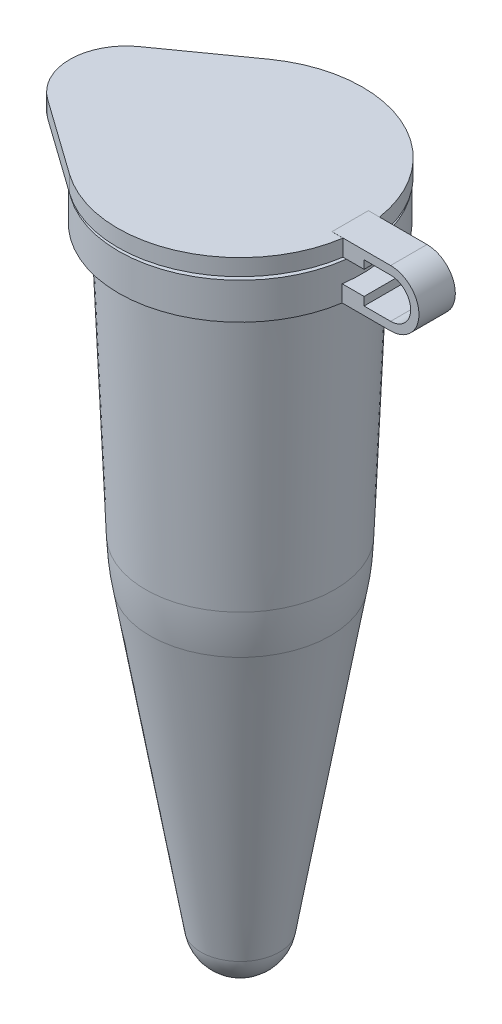
from build123d import *

# Parameters (mm, degrees)
SKETCH1_R           = 3.7338
SKETCH1_R_2         = 2.6797
BOSS_EXTRUDE1_DEPTH = 1.1176
SHELL1_T            = -0.5715
BOSS_EXTRUDE2_DEPTH = 0.5588
SKETCH4_R           = 2.615046293
SKETCH4_R_2         = 2.107046293
BOSS_EXTRUDE3_DEPTH = 1.1176
BOSS_EXTRUDE4_DEPTH = 0.508


with BuildPart() as part:
    # Sketch1 → Boss-Extrude1 (new body)
    with BuildSketch(Plane(origin=(0, 0, 0), x_dir=(1, 0, 0), z_dir=(0, 1, 0))):
        Circle(SKETCH1_R)
        Circle(SKETCH1_R_2, mode=Mode.SUBTRACT)
    extrude(amount=-BOSS_EXTRUDE1_DEPTH)


with BuildPart() as body_2:
    # Sketch2 → Revolve1 (revolve)
    with BuildSketch(Plane.XY):
        with BuildLine():
            Line((0, -1.1176), (0, -20.9296))
            ThreePointArc((0, -20.9296), (-0.789505828, -20.640890822), (-1.206518449, -19.910977871))
            Line((-1.206518449, -19.910977871), (-2.770770199, -10.714786652))
            ThreePointArc((-2.770770199, -10.714786652), (-2.859495986, -10.068144543), (-2.906518408, -9.4171398))
            Line((-2.906518408, -9.4171398), (-3.2385, -1.1176))
            Line((-3.2385, -1.1176), (0, -1.1176))
        make_face()
    revolve(axis=Axis((0, -1.1176, 0), (0, -1, 0)))

    # Shell1
    shell1_openings = [body_2.faces().sort_by_distance(p)[0] for p in [
        (0, -1.1176, 0),
    ]]
    offset(amount=SHELL1_T, openings=shell1_openings, kind=Kind.INTERSECTION)


with BuildPart() as part_1:
    add(part.part)

    # Combine1: union body 2
    add(body_2.part)

    # Sketch3 → Boss-Extrude2 (add, symmetric)
    with BuildSketch(Plane.XY):
        with BuildLine():
            Line((3.7338, -1.1176), (4.365322861, -1.1176))
            Line((4.365322861, -1.1176), (5.180035681, -1.1176))
            ThreePointArc((5.180035681, -1.1176), (6.050241958, -0.247393722), (5.180035681, 0.622812555))
            Line((5.180035681, 0.622812555), (4.365322861, 0.622812555))
            Line((4.365322861, 0.622812555), (3.379294532, 0.622812555))
            Line((3.379294532, 0.622812555), (3.379294532, 0.112660745))
            Line((3.379294532, 0.112660745), (4.365322861, 0.112660745))
            Line((4.365322861, 0.112660745), (4.365322861, 0.36773665))
            Line((4.365322861, 0.36773665), (5.180035681, 0.36773665))
            ThreePointArc((5.180035681, 0.36773665), (5.795166053, -0.247393722), (5.180035681, -0.862524095))
            Line((5.180035681, -0.862524095), (4.365322861, -0.862524095))
            Line((4.365322861, -0.862524095), (4.365322861, -0.607448189))
            Line((4.365322861, -0.607448189), (3.379294532, -0.607448189))
            Line((3.379294532, -0.607448189), (3.379294532, -1.1176))
            Line((3.379294532, -1.1176), (3.7338, -1.1176))
        make_face()
    extrude(amount=BOSS_EXTRUDE2_DEPTH, both=True)



with BuildPart() as body_2_2:
    # Sketch4 → Boss-Extrude3 (new body)
    with BuildSketch(Plane.XZ.offset(-0.112660745)):
        Circle(SKETCH4_R)
        Circle(SKETCH4_R_2, mode=Mode.SUBTRACT)
    extrude(amount=BOSS_EXTRUDE3_DEPTH)


with BuildPart() as part_2:
    add(part_1.part)

    add(body_2_2.part)  # Boss-Extrude4 merges body 2 2
    # Sketch6 → Boss-Extrude4 (add)
    with BuildSketch(Plane.XZ.offset(-0.112660745)):
        with BuildLine():
            Line((-2.179935272, -3.062591525), (-4.50743423, -1.405890971))
            ThreePointArc((-4.50743423, -1.405890971), (-5.2324, 0), (-4.50743423, 1.405890971))
            Line((-4.50743423, 1.405890971), (-2.179935272, 3.062591525))
            ThreePointArc((-2.179935272, 3.062591525), (3.7592, 0), (-2.179935272, -3.062591525))
        make_face()
    extrude(amount=-BOSS_EXTRUDE4_DEPTH)


solid = part_2.part
